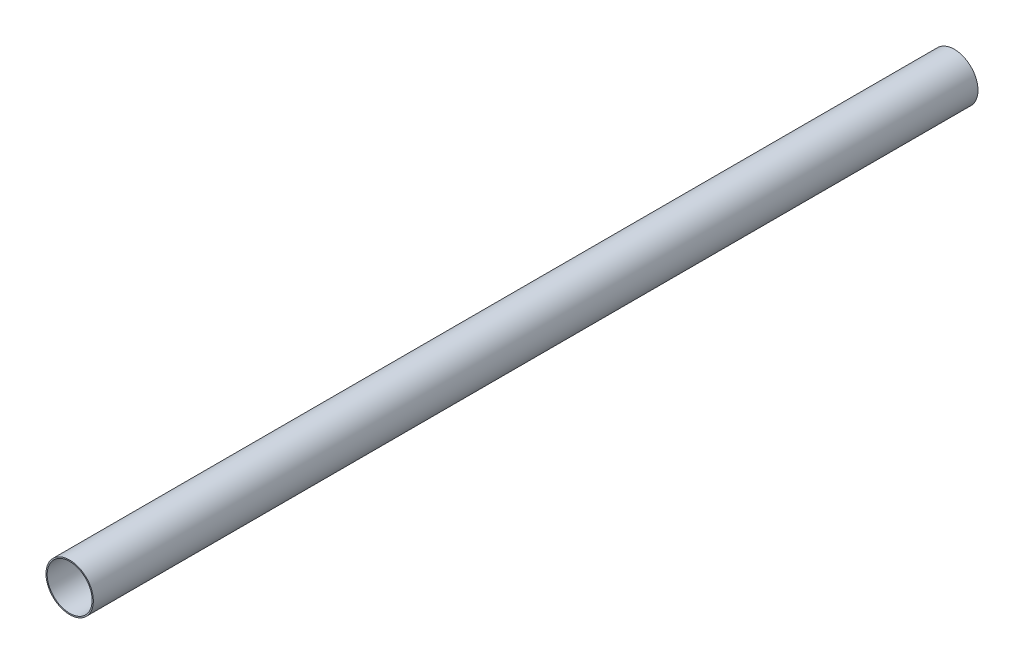
from build123d import *

# Parameters (mm, degrees)
SKIZZE1_R                       = 37.5
AUFSATZ_LINEAR_AUSTRAGEN2_DEPTH = 1400
WANDUNG2_T                      = -1.9


with BuildPart() as part:
    # Skizze1 → Aufsatz-Linear austragen2 (new body)
    with BuildSketch(Plane.XY):
        Circle(SKIZZE1_R)
    extrude(amount=AUFSATZ_LINEAR_AUSTRAGEN2_DEPTH)

    # Wandung2
    wandung2_openings = [part.faces().sort_by_distance(p)[0] for p in [
        (0, 0, 0),
        (0, 0, 1400),
    ]]
    offset(amount=WANDUNG2_T, openings=wandung2_openings, kind=Kind.INTERSECTION)


solid = part.part
